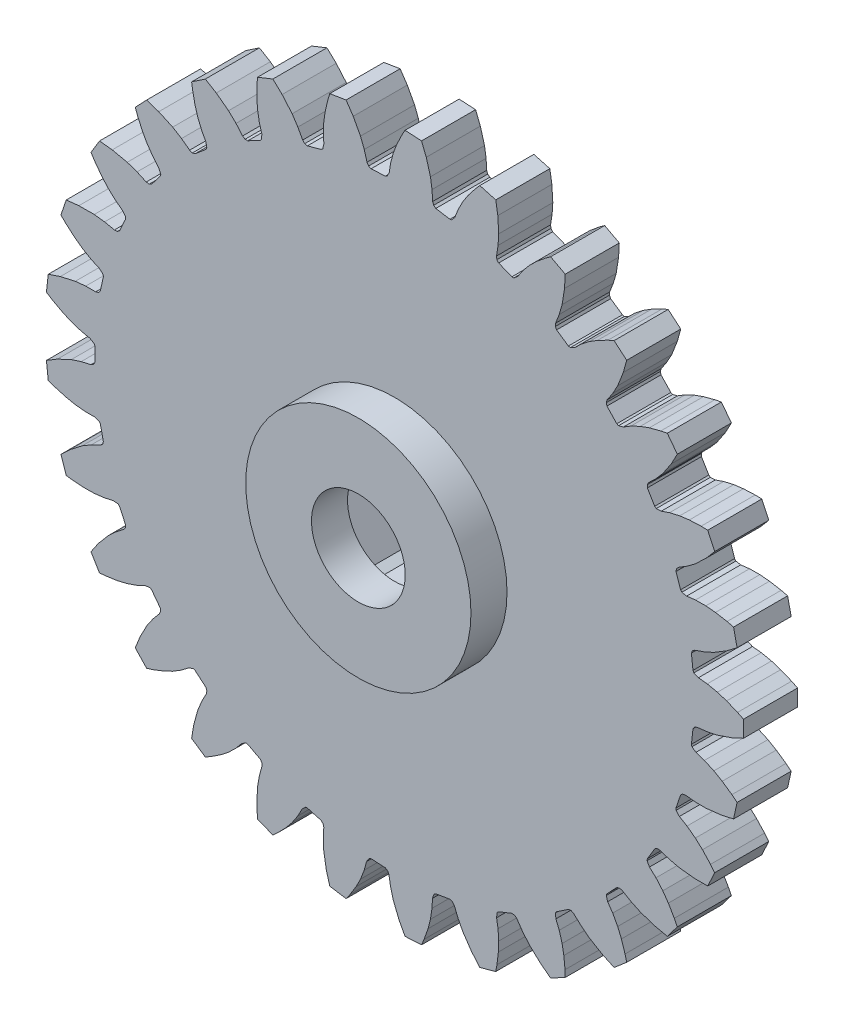
from build123d import *

# Parameters (mm, degrees)
BOSS_EXTRUDE1_DEPTH = 6
CUT_EXTRUDE2_DEPTH  = 6
SKETCH7_R           = 12.5
BOSS_EXTRUDE3_DEPTH = 4
SKETCH8_R           = 5.2
CUT_EXTRUDE3_DEPTH  = 10


with BuildPart() as part:
    # Sketch2 → Boss-Extrude1 (new body)
    with BuildSketch(Plane.XY):
        Polygon((13.040293, 30.586224), (13.258226, 30.585831), (13.682392, 30.929327), (14.227458, 31.746732), (14.965217, 32.634405), (15.730459, 33.385182), (16.738475, 34.22115), (17.335007, 34.656286), (18.956445, 33.796654), (18.879431, 32.38367), (18.612851, 30.700551), (18.292156, 29.591766), (17.886914, 28.549486), (17.860225, 28.222161), (17.997837, 27.9579), (19.310551908, 27.067857208), (19.523305272, 27.020624243), (20.011395993, 27.264906346), (20.719436566, 27.946027793), (21.630770626, 28.654351115), (22.539516556, 29.223070956), (23.703674111, 29.822800845), (24.379800901, 30.119526861), (25.778535113, 28.931431339), (25.399571865, 27.568037853), (24.777403524, 25.98157606), (24.225850196, 24.967653782), (23.606023138, 24.03685676), (23.509592913, 23.722921783), (23.587179317, 23.435256546), (24.67787079, 22.283827558), (24.875496407, 22.191963189), (25.404689269, 22.325609035), (26.242597224, 22.838598448), (27.284893377, 23.33445168), (28.294651286, 23.694521655), (29.560515683, 24.029970731), (30.284622327, 24.174412183), (31.395249492, 22.713407165), (30.732056897, 21.463354957), (29.783392116, 20.047731561), (29.02677048, 19.176081885), (28.221340789, 18.400290876), (28.059678308, 18.114425172), (28.073611263, 17.816806605), (28.891279778, 16.457830961), (29.064536895, 16.325630664), (29.610087429, 16.342391121), (30.538683121, 16.663261685), (31.663204756, 16.923459281), (32.726759488, 17.058042918), (34.035140314, 17.113525954), (34.77336839, 17.098928921), (35.543956817, 15.433329378), (34.627545022, 14.355069501), (33.396742313, 13.176477478), (32.470431155, 12.487857773), (31.517059828, 11.903347902), (31.29772425, 11.658918234), (31.247352266, 11.36526265), (31.753764553, 9.862284541), (31.894551859, 9.695929855), (32.430950727, 9.595021224), (33.406814054, 9.708769387), (34.56097979, 9.721144797), (35.628600707, 9.623949114), (36.918319529, 9.396871786), (37.636150312, 9.223918809), (38.030668143, 7.431606324), (36.903887547, 6.575557011), (35.448497875, 5.689106015), (34.395810476, 5.215715373), (33.339076096, 4.849817672), (33.072323309, 4.658253299), (32.960001724, 4.382291708), (33.131478507, 2.805588719), (33.233212944, 2.612858204), (33.735378732, 2.39899886), (34.71287941, 2.300305885), (35.842721739, 2.064280449), (36.864488074, 1.739850209), (38.075239073, 1.240830399), (38.739107594, 0.917608567), (38.73910786, -0.917610409), (37.454645464, -1.511421231), (35.842721227, -2.06428172), (34.712880077, -2.300308066), (33.602194369, -2.430484615), (33.300497435, -2.560226352), (33.131478278, -2.805590293), (32.960001478, -4.38229328), (33.017926054, -4.59238776), (33.462378044, -4.909197996), (34.395809224, -5.215717345), (35.448497971, -5.689107352), (36.376633058, -6.225602162), (37.451802856, -6.973230852), (38.030667356, -7.431608052), (37.636149544, -9.223920541), (36.254065391, -9.527726949), (34.560978384, -9.721145804), (33.406813605, -9.708771535), (32.294111001, -9.597140034), (31.971576936, -9.658992558), (31.753763359, -9.862285904), (31.247351055, -11.365264008), (31.258757284, -11.582898667), (31.624713397, -11.987846097), (32.470428876, -12.487859305), (33.396741486, -13.17647868), (34.187846766, -13.899952148), (35.077161623, -14.86123142), (35.543955044, -15.433330771), (34.773366634, -17.098930323), (33.358285443, -17.098526667), (31.663202534, -16.923459837), (30.538681588, -16.663263562), (29.475990826, -16.315043774), (29.147700963, -16.306114931), (28.891277686, -16.45783191), (28.073609156, -17.816807546), (28.037963695, -18.03180603), (28.308312231, -18.50595576), (29.026767292, -19.176082766), (29.783390418, -20.047732433), (30.400474687, -20.924355743), (31.062351228, -22.054337246), (31.395246829, -22.71340802), (30.284619679, -24.17441305), (28.902709071, -23.869818219), (27.284890445, -23.334451652), (26.242594677, -22.83859987), (25.279605989, -22.270074177), (24.960910797, -22.190781472), (24.677867889, -22.283827971), (23.587176417, -23.435256959), (23.506146011, -23.637566178), (23.668245777, -24.158747493), (24.225846269, -24.967653897), (24.777401065, -25.98157648), (25.191610158, -26.970359696), (25.595099786, -28.216206747), (25.778531746, -28.931431524), (24.37979756, -30.119527076), (23.095674138, -29.524983572), (21.6307672, -28.654350396), (20.719433203, -27.946028572), (19.901174874, -27.183780592), (19.606976186, -27.03783166), (19.310548418, -27.067856925), (17.997833509, -27.957899718), (17.875207047, -28.138059918), (17.921478434, -28.681902961), (18.292151571, -29.591765206), (18.612847939, -30.70055082), (18.804813889, -31.755259545), (18.931049865, -33.058717727), (18.956441102, -33.796653395), (17.335003121, -34.65628543), (16.20871107, -33.799593445), (14.965213239, -32.6344035), (14.227453979, -31.746731976), (13.592186859, -30.826403577), (13.336241079, -30.620622829), (13.040289082, -30.586222912), (11.566931828, -31.173262097), (11.408443187, -31.322849187), (11.336722596, -31.863924463), (11.503136114, -32.832198401), (11.577978647, -33.984001462), (11.538725342, -35.055318689), (11.381805011, -36.355439746), (11.24796826, -37.081581254), (9.47964312, -37.572554333), (8.563846605, -36.493771832), (7.599902458, -35.088508104), (7.070214738, -34.062993415), (6.647643211, -33.027618129), (6.441918079, -32.771627644), (6.160280241, -32.674411047), (4.595173188, -32.930997325), (4.408233121, -33.043016779), (4.221874128, -33.556024209), (4.176246715, -34.537434427), (4.00173586, -35.678397906), (3.733098739, -36.716230031), (3.300359523, -37.952221747), (3.013552841, -38.632615525), (1.181025462, -38.731972292), (0.518546109, -37.481541947), (-0.120771398, -35.901913006), (-0.417619969, -34.786507078), (-0.607736927, -33.684497904), (-0.753621933, -33.390267512), (-1.00777654, -33.234779975), (-2.591450724, -33.148915656), (-2.798101108, -33.218129569), (-3.090384565, -33.679081495), (-3.345919421, -34.627738343), (-3.76162373, -35.704512054), (-4.247083493, -36.660331201), (-4.93540719, -37.774399978), (-5.361773041, -38.377231569), (-7.172815717, -38.080326212), (-7.551001109, -36.716716756), (-7.835798198, -35.036584296), (-7.885927312, -33.883442271), (-7.834700044, -32.766327933), (-7.913923502, -32.44761552), (-8.128710892, -32.241127467), (-9.656901363, -31.816827472), (-9.873599321, -31.839999478), (-10.258140392, -32.227342301), (-10.711634165, -33.098887639), (-11.349094057, -34.06112284), (-12.028676903, -34.890235967), (-12.940399831, -35.830289188), (-13.486388457, -36.327370856), (-15.191264086, -35.648086341), (-15.267471989, -34.235058635), (-15.184431866, -32.532983783), (-14.98549754, -31.3960253), (-14.695321377, -30.316040822), (-14.704178886, -29.987749027), (-14.869555839, -29.739915611), (-16.270806109, -28.997019735), (-16.487419086, -28.973066337), (-16.946237057, -29.268688337), (-17.576484883, -30.022369673), (-18.405893441, -30.825073317), (-19.247822832, -31.488712016), (-20.340313839, -32.210793835), (-20.98039542, -32.578882595), (-22.499385913, -31.548981509), (-22.270052929, -30.15260716), (-21.823058458, -28.508177044), (-21.38436264, -27.440565018), (-20.868805896, -26.448209275), (-20.80688329, -26.125688657), (-20.915116963, -25.848098292), (-22.123906127, -24.821343521), (-22.33030554, -24.751384753), (-22.841946593, -24.941462974), (-23.619478784, -25.542039006), (-24.602053787, -26.147677562), (-25.56696204, -26.614810826), (-26.789137461, -27.085157501), (-27.493382493, -27.30704193), (-28.755461542, -25.974681305), (-28.231311028, -24.660253225), (-27.441263173, -23.150359569), (-26.783318792, -22.202014352), (-26.066488327, -21.343688795), (-25.936681038, -21.042020059), (-25.982710545, -20.747652563), (-26.942516965, -19.485048809), (-27.129051808, -19.372355866), (-27.669592176, -19.448002461), (-28.55805219, -19.867390922), (-29.647849523, -20.247645404), (-30.6906186, -20.496430599), (-31.985330871, -20.693049242), (-32.720809639, -20.758354273), (-33.666963831, -19.18583381), (-32.872504481, -18.014813195), (-31.776345003, -16.710056948), (-30.929916807, -15.925322108), (-30.045330817, -15.241161087), (-29.85370849, -14.974449929), (-29.835381542, -14.677069597), (-30.501325736, -13.237654809), (-30.659273846, -13.087497087), (-31.203438463, -13.045174906), (-32.161282898, -13.263765657), (-33.307344848, -13.400855789), (-34.379216027, -13.419659997), (-35.68592584, -13.333356938), (-36.418248174, -13.239028979), (-37.004236392, -11.499877987), (-35.976616243, -10.527020459), (-34.625600339, -9.488410575), (-33.63026637, -8.903979441), (-32.619287113, -8.425973564), (-32.374809794, -8.2066911), (-32.292983339, -7.920203108), (-32.633926498, -6.371282721), (-32.755902397, -6.190681428), (-33.27824673, -6.032369409), (-34.260687844, -6.03994139), (-35.409425829, -5.927456989), (-36.460279604, -5.715400946), (-37.717886661, -5.350211621), (-38.412809983, -5.100661343), (-38.611232067, -3.276200589), (-37.398501495, -2.546995885), (-35.855801169, -1.823096606), (-34.758102137, -1.466296529), (-33.668001879, -1.21679682), (-33.382101056, -1.055196455), (-33.240601208, -0.792996662), (-33.240601208, 0.793003528), (-33.320901439, 0.995603676), (-33.797001247, 1.262503039), (-34.758101187, 1.466303885), (-35.855801494, 1.823103174), (-36.836501111, 2.256103964), (-37.986201104, 2.883103707), (-38.611231572, 3.276207612), (-38.412809527, 5.100668369), (-37.071674466, 5.552123447), (-35.409424668, 5.927463395), (-34.26068776, 6.03994884), (-33.142438379, 6.049276053), (-32.828482457, 6.145638065), (-32.633925591, 6.371289489), (-32.292982432, 7.920209875), (-32.327852245, 8.13533552), (-32.735445631, 8.49834231), (-33.63026443, 8.903986483), (-34.625599814, 9.488417121), (-35.490288849, 10.122116021), (-36.478323084, 10.981608373), (-37.004234968, 11.499884801), (-36.418246788, 13.239035805), (-35.011417222, 13.39163172), (-33.307342907, 13.400861858), (-32.161281784, 13.263772977), (-31.067171376, 13.032491563), (-30.739840585, 13.059109442), (-30.501323966, 13.237661286), (-29.835379771, 14.677076074), (-29.823188692, 14.894668179), (-30.143217042, 15.336808602), (-30.929913968, 15.92532863), (-31.776343653, 16.710063291), (-32.484590207, 17.514829245), (-33.264759302, 18.566625297), (-33.666961546, 19.18584022), (-32.720807386, 20.758360703), (-31.314065103, 20.604962239), (-29.647846892, 20.247650976), (-28.558050098, 19.867397893), (-27.539238051, 19.406322314), (-27.213838015, 19.361951437), (-26.942514413, 19.485054815), (-25.982707993, 20.747658569), (-25.924026064, 20.957542771), (-26.141525207, 21.458142831), (-26.783315187, 22.202020173), (-27.44126106, 23.150365535), (-27.959948312, 24.088568581), (-28.495772427, 25.283487521), (-28.755458502, 25.974687136), (-27.49337948, 27.307047788), (-26.152502185, 26.854827687), (-24.60205059, 26.1476825), (-23.619475812, 25.542045427), (-22.723600644, 24.872735064), (-22.415346707, 24.759450165), (-22.123902913, 24.8213489), (-20.915113749, 25.848103671), (-20.812684872, 26.040466017), (-20.91748479, 26.576118212), (-21.384358438, 27.44056999), (-21.823055682, 28.508182478), (-22.127930392, 29.535953286), (-22.394354986, 30.81812203), (-22.499382259, 31.548986612), (-20.980391788, 32.57888773), (-19.768077413, 31.848991301), (-18.405889827, 30.825077514), (-17.576481169, 30.022375366), (-16.845433009, 29.176126428), (-16.568738782, 28.999224583), (-16.270802383, 28.997024359), (-14.869552113, 29.739920235), (-14.728165748, 29.905766075), (-14.715366114, 30.451423905), (-14.985492936, 31.396029314), (-15.184428556, 32.532988555), (-15.261235122, 33.602269703), (-15.245802478, 34.911735467), (-15.191259991, 35.6480906), (-13.486384376, 36.327375152), (-12.459319394, 35.353931541), (-11.349090194, 34.061126224), (-10.711629884, 33.098892462), (-10.17959173, 32.11527461), (-9.947395128, 31.883027551), (-9.6568973, 31.816831249), (-8.128706828, 32.241131245), (-7.954974045, 32.372705812), (-7.825173356, 32.902854922), (-7.885922522, 33.883445263), (-7.835794509, 35.036588307), (-7.680941541, 36.097381397), (-7.384373272, 37.372915017), (-7.17281137, 38.080329554), (-5.361768701, 38.377234949), (-4.567977529, 37.205761298), (-3.761619799, 35.704514591), (-3.345914772, 34.627742196), (-3.037764138, 33.552748306), (-2.860922415, 33.276015649), (-2.591446513, 33.148918533), (-1.007772329, 33.234782853), (-0.809816679, 33.325933867), (-0.56908427, 33.815785074), (-0.417615217, 34.786509033), (-0.120767502, 35.901916192), (0.258504247, 36.904619719), (0.822340939, 38.08657866), (1.181029855, 38.731974683), (3.013557237, 38.632617955), (3.536957806, 37.317891069), (4.001739675, 35.6783996), (4.176251513, 34.537437252), (4.246105848, 33.421332845), (4.359323768, 33.1130543), (4.59517735, 32.930999291), (6.160284402, 32.674413014), (6.373206733, 32.720878355), (6.713614482, 33.147526761), (7.070219229, 34.062994365), (7.599906378, 35.08851044), (8.185862583, 35.986239101), (8.99060332, 37.019356277), (9.479647356, 37.572555785), (11.247972506, 37.081582745), (11.476508843, 35.685077792), (11.577982168, 33.984002359), (11.503140838, 32.832200191), (11.331432561, 31.727173067), (11.375732735, 31.401763397), (11.566935746, 31.173263185), align=None)
    extrude(amount=BOSS_EXTRUDE1_DEPTH)

    # Sketch6 → Cut-Extrude2 (cut)
    with BuildSketch(Plane(origin=(0, 0, 0), x_dir=(-1, 0, 0), z_dir=(0, 0, -1))):
        Polygon((4, 8), (-4, 8), (-4.92820323, 7.464101615), (-8.92820323, 0.535898385), (-8.92820323, -0.535898385), (-4.92820323, -7.464101615), (-4, -8), (4, -8), (4.92820323, -7.464101615), (8.92820323, -0.535898385), (8.92820323, 0.535898385), (4.92820323, 7.464101615), align=None)
    extrude(amount=-CUT_EXTRUDE2_DEPTH, mode=Mode.SUBTRACT)

    # Sketch7 → Boss-Extrude3 (add)
    with BuildSketch(Plane.XY.offset(6)):
        Circle(SKETCH7_R)
    extrude(amount=BOSS_EXTRUDE3_DEPTH)

    # Sketch8 → Cut-Extrude3 (cut)
    with BuildSketch(Plane.XY.offset(10)):
        Circle(SKETCH8_R)
    extrude(amount=-CUT_EXTRUDE3_DEPTH, mode=Mode.SUBTRACT)


solid = part.part
